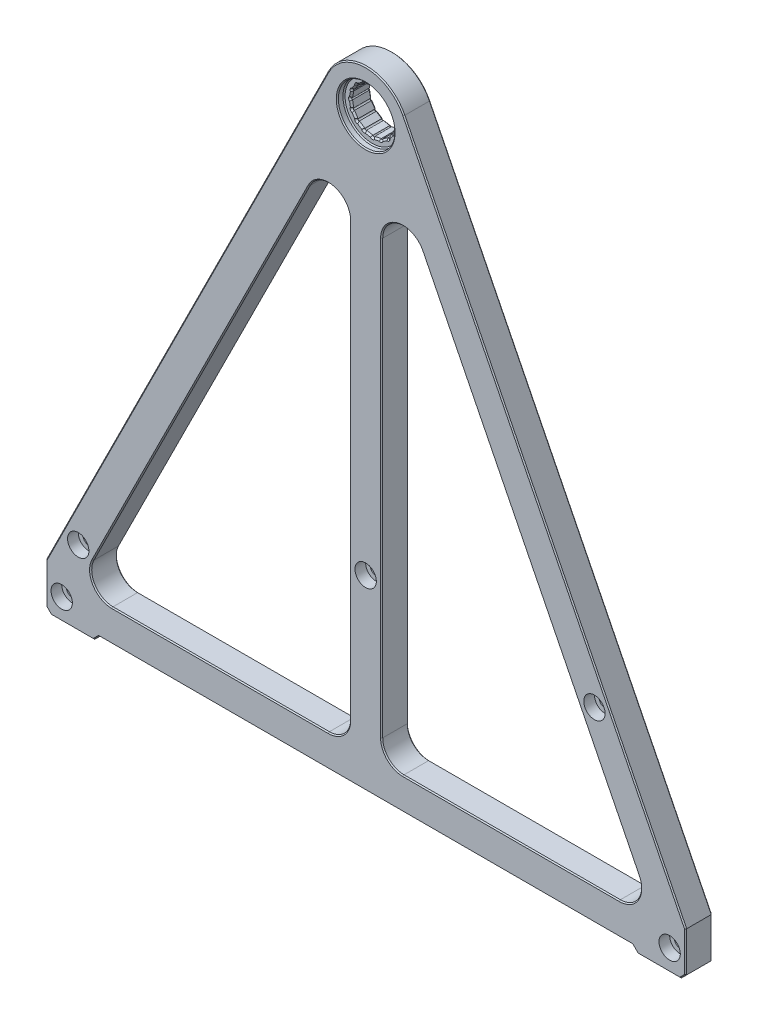
from build123d import *

# Parameters (mm, degrees)
BOSS_EXTRUDE1_DEPTH            = 5
FILLET14_R                     = 16
CUT_EXTRUDE3_DEPTH             = 11
CUT_EXTRUDE2_DEPTH             = 11
FILLET17_R                     = 8
FILLET20_R                     = 8
FILLET19_R                     = 8
BOSS_EXTRUDE2_DEPTH            = 10
CHAMFER3_SIZE                  = 0.4
CBORE_FOR_M4_SHCS1_D           = 4.5
CBORE_FOR_M4_SHCS1_CBORE_D     = 8
CBORE_FOR_M4_SHCS1_CBORE_DEPTH = 4
CBORE_FOR_M4_SHCS2_D           = 4.5
CBORE_FOR_M4_SHCS2_CBORE_D     = 8
CBORE_FOR_M4_SHCS2_CBORE_DEPTH = 4
CUT_EXTRUDE4_DEPTH             = 11
SKETCH17_R                     = 0.35
CUT_EXTRUDE5_DEPTH             = 11
SKETCH18_R                     = 10.625
CUT_EXTRUDE6_DEPTH             = 2.5
CHAMFER2_SIZE                  = 0.6
CHAMFER4_SIZE                  = 0.4


with BuildPart() as part:
    # Sketch1 → Boss-Extrude1 (new body, symmetric)
    with BuildSketch(Plane.XY):
        Polygon((0, 255), (127.5, 0), (0, 0), (-127.5, 0), align=None)
    extrude(amount=BOSS_EXTRUDE1_DEPTH, both=True)

    # Fillet14
    fillet14_edges = [part.edges().sort_by_distance(p)[0] for p in [
        (0, 255, 0),
    ]]
    fillet(fillet14_edges, radius=FILLET14_R)

    # Sketch8 → Cut-Extrude3 (cut, through all)
    with BuildSketch(Plane.XY.offset(5)):
        Polygon((-108.083592135, 12), (-6, 216.16718427), (-6, 12), align=None)
        Polygon((6, 12), (6, 216.16718427), (108.083592135, 12), align=None)
    extrude(amount=-CUT_EXTRUDE3_DEPTH, mode=Mode.SUBTRACT)

    # Sketch7 → Cut-Extrude2 (cut, through all)
    with BuildSketch(Plane.XY.offset(5)):
        Polygon((-120, 15), (-120, 0), (-127.5, 0), align=None)
        Polygon((120, 15), (120, 0), (127.5, 0), align=None)
    extrude(amount=-CUT_EXTRUDE2_DEPTH, mode=Mode.SUBTRACT)

    # Fillet17
    fillet17_edges = [part.edges().sort_by_distance(p)[0] for p in [
        (-6, 216.16718427, 0),
    ]]
    fillet(fillet17_edges, radius=FILLET17_R)

    # Fillet20
    fillet20_edges = [part.edges().sort_by_distance(p)[0] for p in [
        (6, 216.16718427, 0),
    ]]
    fillet(fillet20_edges, radius=FILLET20_R)

    # Fillet19
    fillet19_edges = [part.edges().sort_by_distance(p)[0] for p in [
        (-6, 12, 0),
        (-108.083592135, 12, 0),
        (108.083592135, 12, 0),
        (6, 12, 0),
    ]]
    fillet(fillet19_edges, radius=FILLET19_R)

    # Sketch15 → Boss-Extrude2 (add, through all)
    with BuildSketch(Plane.XY.offset(5)):
        Polygon((-120, 0), (-100, 0), (-102, -2), (-118, -2), align=None)
        Polygon((120, 0), (100, 0), (102, -2), (118, -2), align=None)
    extrude(amount=-BOSS_EXTRUDE2_DEPTH)

    # Chamfer3
    chamfer3_edges = [part.edges().sort_by_distance(p)[0] for p in [
        (0, 0, 5),
        (0, 0, -5),
        (-119, -1, -5),
        (-101, -1, -5),
        (-110, -2, -5),
        (-119, -1, 5),
        (-110, -2, 5),
        (-101, -1, 5),
        (119, -1, -5),
        (110, -2, -5),
        (101, -1, -5),
        (119, -1, 5),
        (101, -1, 5),
        (110, -2, 5),
        (-67.155417528, 120.689164944, -5),
        (-67.155417528, 120.689164944, 5),
        (0, 235.22291236, -5),
        (0, 235.22291236, 5),
        (67.155417528, 120.689164944, -5),
        (67.155417528, 120.689164944, 5),
        (-120, 7.5, -5),
        (-120, 7.5, 5),
        (120, 7.5, -5),
        (120, 7.5, 5),
        (-61.725077641, 104.717028989, 5),
        (-61.725077641, 104.717028989, -5),
        (-12.161976636, 190.064632366, 5),
        (-12.161976636, 190.064632366, -5),
        (6, 101.139320225, 5),
        (6, 101.139320225, -5),
        (12.161976636, 190.064632366, 5),
        (12.161976636, 190.064632366, -5),
        (61.725077641, 104.717028989, 5),
        (61.725077641, 104.717028989, -5),
        (54.569660113, 12, 5),
        (54.569660113, 12, -5),
        (-6, 101.139320225, 5),
        (-6, 101.139320225, -5),
        (-54.569660113, 12, 5),
        (-54.569660113, 12, -5),
        (101.944526692, 15.794151103, 5),
        (101.944526692, 15.794151103, -5),
        (8.343145751, 14.343145751, 5),
        (8.343145751, 14.343145751, -5),
        (-8.343145751, 14.343145751, 5),
        (-8.343145751, 14.343145751, -5),
        (-101.944526692, 15.794151103, 5),
        (-101.944526692, 15.794151103, -5),
    ]]
    chamfer(chamfer3_edges, length=CHAMFER3_SIZE)

    # CBORE for M4 SHCS1 (through all)
    with Locations(Plane.XY.offset(5)):
        with Locations((0, 70), (85.791796068, 70), (-107.791796068, 26)):
            CounterBoreHole(CBORE_FOR_M4_SHCS1_D / 2, CBORE_FOR_M4_SHCS1_CBORE_D / 2, CBORE_FOR_M4_SHCS1_CBORE_DEPTH)

    # CBORE for M4 SHCS2 (through all)
    with Locations(Plane.XY.offset(5)):
        with Locations((-114, 6), (114, 6)):
            CounterBoreHole(CBORE_FOR_M4_SHCS2_D / 2, CBORE_FOR_M4_SHCS2_CBORE_D / 2, CBORE_FOR_M4_SHCS2_CBORE_DEPTH)

    # Sketch16 → Cut-Extrude4 (cut, through all)
    with BuildSketch(Plane.XY.offset(5)):
        Polygon((0, 227.32291236), (-3.099735802, 226.706336573), (-5.727564928, 224.950477288), (-7.483424213, 222.322648162), (-8.1, 219.22291236), (-7.483424213, 216.123176558), (-5.727564928, 213.495347432), (-3.099735802, 211.739488147), (0, 211.12291236), (3.099735802, 211.739488147), (5.727564928, 213.495347432), (7.483424213, 216.123176558), (8.1, 219.22291236), (7.483424213, 222.322648162), (5.727564928, 224.950477288), (3.099735802, 226.706336573), align=None)
    extrude(amount=-CUT_EXTRUDE4_DEPTH, mode=Mode.SUBTRACT)

    # Sketch17 → Cut-Extrude5 (cut, through all)
    with BuildSketch(Plane.XY.offset(5)):
        with Locations((0, 227.22291236)):
            Circle(SKETCH17_R)
        with Locations((3.061467459, 226.61394862)):
            Circle(SKETCH17_R)
        with Locations((5.656854249, 224.879766609)):
            Circle(SKETCH17_R)
        with Locations((7.39103626, 222.284379819)):
            Circle(SKETCH17_R)
        with Locations((8, 219.22291236)):
            Circle(SKETCH17_R)
        with Locations((7.39103626, 216.161444901)):
            Circle(SKETCH17_R)
        with Locations((5.656854249, 213.566058111)):
            Circle(SKETCH17_R)
        with Locations((3.061467459, 211.8318761)):
            Circle(SKETCH17_R)
        with Locations((0, 211.22291236)):
            Circle(SKETCH17_R)
        with Locations((-3.061467459, 211.8318761)):
            Circle(SKETCH17_R)
        with Locations((-5.656854249, 213.566058111)):
            Circle(SKETCH17_R)
        with Locations((-7.39103626, 216.161444901)):
            Circle(SKETCH17_R)
        with Locations((-8, 219.22291236)):
            Circle(SKETCH17_R)
        with Locations((-7.39103626, 222.284379819)):
            Circle(SKETCH17_R)
        with Locations((-5.656854249, 224.879766609)):
            Circle(SKETCH17_R)
        with Locations((-3.061467459, 226.61394862)):
            Circle(SKETCH17_R)
    extrude(amount=-CUT_EXTRUDE5_DEPTH, mode=Mode.SUBTRACT)

    # Sketch18 → Cut-Extrude6 (cut)
    with BuildSketch(Plane.XY.offset(5)):
        with Locations((0, 219.22291236)):
            Circle(SKETCH18_R)
    extrude(amount=-CUT_EXTRUDE6_DEPTH, mode=Mode.SUBTRACT)

    # Chamfer2
    chamfer2_edges = [part.edges().sort_by_distance(p)[0] for p in [
        (-1.549867901, 227.014624467, -5),
        (-4.413650365, 225.82840693, -5),
        (-6.60549457, 223.636562725, -5),
        (-7.791712107, 220.772780261, -5),
        (-7.791712107, 217.673044459, -5),
        (-6.60549457, 214.809261995, -5),
        (-4.413650365, 212.61741779, -5),
        (-1.549867901, 211.431200253, -5),
        (1.549867901, 211.431200253, -5),
        (4.413650365, 212.61741779, -5),
        (6.60549457, 214.809261995, -5),
        (7.791712107, 217.673044459, -5),
        (7.791712107, 220.772780261, -5),
        (6.60549457, 223.636562725, -5),
        (4.413650365, 225.82840693, -5),
        (1.549867901, 227.014624467, -5),
        (-3.19540666, 226.937306456, -5),
        (-5.904341623, 225.127253983, -5),
        (-7.714394096, 222.41831902, -5),
        (-8.35, 219.22291236, -5),
        (-7.714394096, 216.0275057, -5),
        (-5.904341623, 213.318570737, -5),
        (-3.19540666, 211.508518264, -5),
        (0, 210.87291236, -5),
        (3.19540666, 211.508518264, -5),
        (5.904341623, 213.318570737, -5),
        (7.714394096, 216.0275057, -5),
        (8.35, 219.22291236, -5),
        (7.714394096, 222.41831902, -5),
        (5.904341623, 225.127253983, -5),
        (3.19540666, 226.937306456, -5),
        (0, 227.57291236, -5),
        (3.19540666, 226.937306456, 2.5),
        (-1.549867901, 211.431200253, 2.5),
        (-3.19540666, 211.508518264, 2.5),
        (-4.413650365, 212.61741779, 2.5),
        (-5.904341623, 213.318570737, 2.5),
        (-6.60549457, 214.809261995, 2.5),
        (-7.714394096, 216.0275057, 2.5),
        (-7.791712107, 217.673044459, 2.5),
        (-8.35, 219.22291236, 2.5),
        (-7.791712107, 220.772780261, 2.5),
        (-7.714394096, 222.41831902, 2.5),
        (-6.60549457, 223.636562725, 2.5),
        (-5.904341623, 225.127253983, 2.5),
        (-4.413650365, 225.82840693, 2.5),
        (-3.19540666, 226.937306456, 2.5),
        (-1.549867901, 227.014624467, 2.5),
        (0, 227.57291236, 2.5),
        (1.549867901, 227.014624467, 2.5),
        (4.413650365, 225.82840693, 2.5),
        (5.904341623, 225.127253983, 2.5),
        (6.60549457, 223.636562725, 2.5),
        (7.714394096, 222.41831902, 2.5),
        (7.791712107, 220.772780261, 2.5),
        (8.35, 219.22291236, 2.5),
        (7.791712107, 217.673044459, 2.5),
        (7.714394096, 216.0275057, 2.5),
        (6.60549457, 214.809261995, 2.5),
        (5.904341623, 213.318570737, 2.5),
        (4.413650365, 212.61741779, 2.5),
        (3.19540666, 211.508518264, 2.5),
        (1.549867901, 211.431200253, 2.5),
        (0, 210.87291236, 2.5),
    ]]
    chamfer(chamfer2_edges, length=CHAMFER2_SIZE)

    # Chamfer4
    chamfer4_edges = [part.edges().sort_by_distance(p)[0] for p in [
        (-10.625, 219.22291236, 5),
        (-10.625, 219.22291236, 2.5),
    ]]
    chamfer(chamfer4_edges, length=CHAMFER4_SIZE)


solid = part.part
